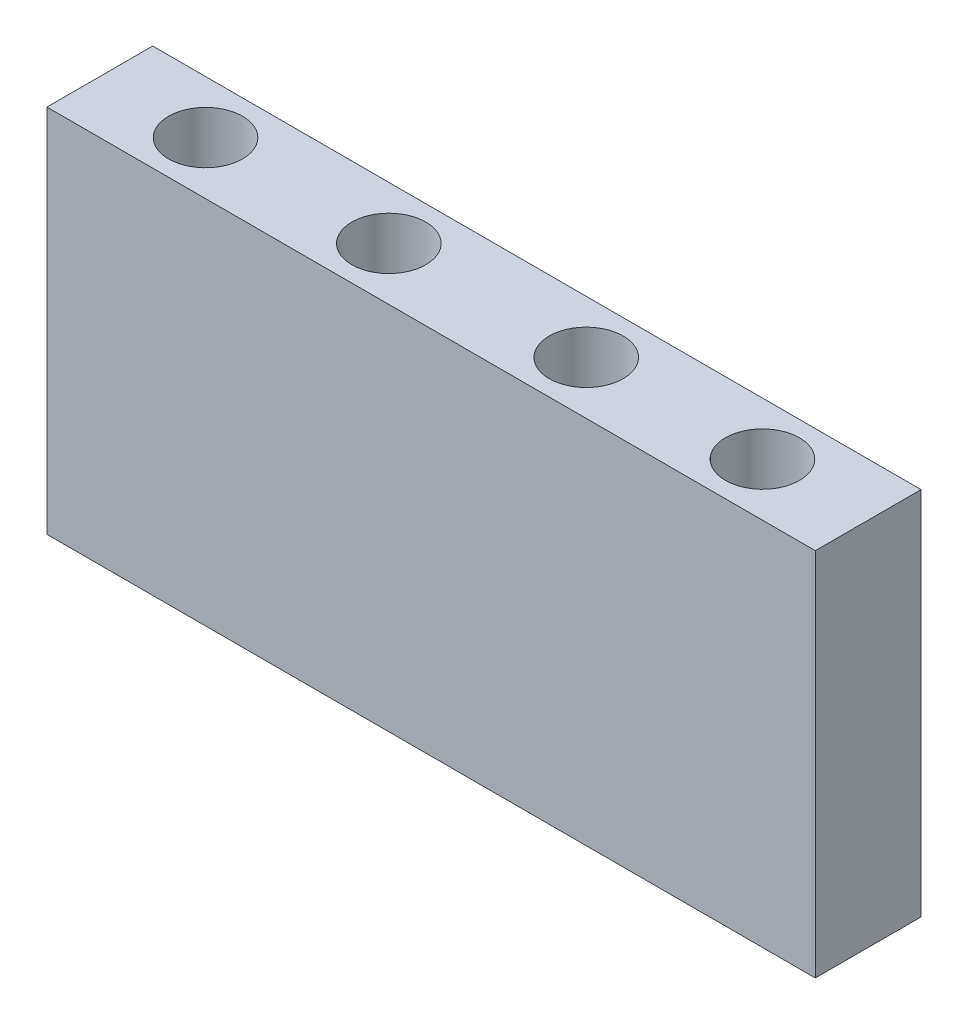
from build123d import *

# Parameters (mm, degrees)
SKIZZE1_W                       = 218
SKIZZE1_H                       = 105
AUFSATZ_LINEAR_AUSTRAGEN1_DEPTH = 30
SKIZZE11_R                      = 10.5
SCHNITT_LINEAR_AUSTRAGEN2_DEPTH = 106


with BuildPart() as part:
    # Skizze1 → Aufsatz-Linear austragen1 (new body)
    with BuildSketch(Plane.XY):
        with Locations((109, 52.5)):
            Rectangle(SKIZZE1_W, SKIZZE1_H)
    extrude(amount=AUFSATZ_LINEAR_AUSTRAGEN1_DEPTH)

    # Skizze11 → Schnitt-Linear austragen2 (cut, through all)
    with BuildSketch(Plane(origin=(0, 105, 0), x_dir=(1, 0, 0), z_dir=(0, 1, 0))):
        with Locations((30, -15)):
            Circle(SKIZZE11_R)
        with Locations((82, -15)):
            Circle(SKIZZE11_R)
        with Locations((138, -15)):
            Circle(SKIZZE11_R)
        with Locations((188, -15)):
            Circle(SKIZZE11_R)
    extrude(amount=-SCHNITT_LINEAR_AUSTRAGEN2_DEPTH, mode=Mode.SUBTRACT)


solid = part.part
